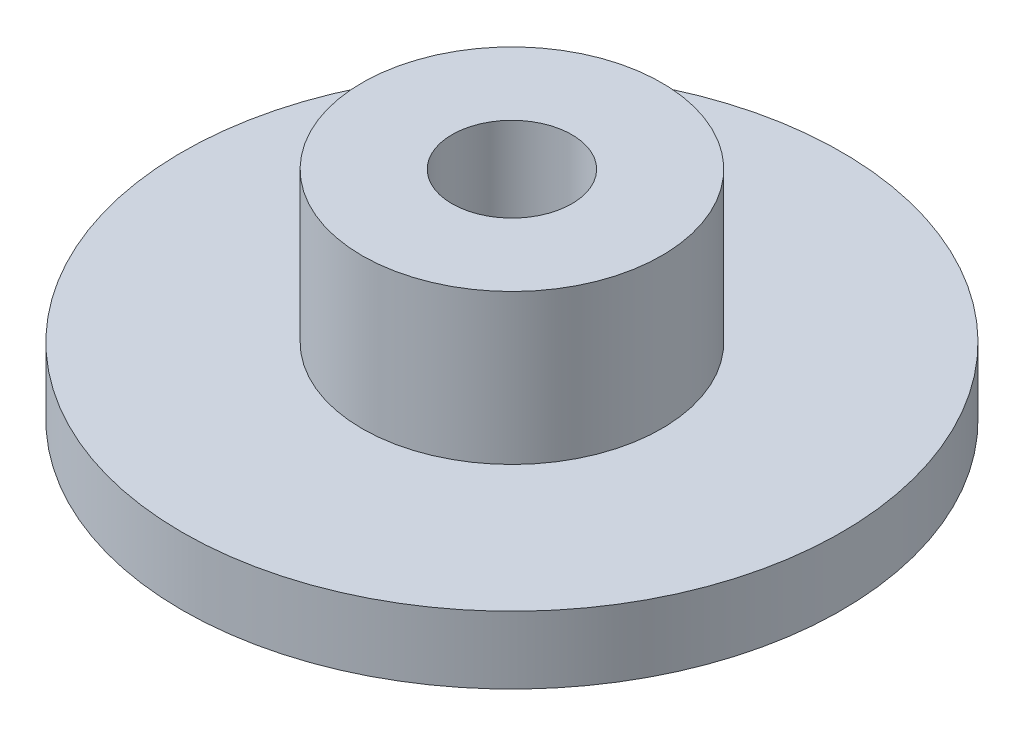
from build123d import *

# Parameters (mm, degrees)
SKETCH1_R           = 22
BOSS_EXTRUDE1_DEPTH = 4.5
SKETCH3_R           = 10
BOSS_EXTRUDE2_DEPTH = 10
SKETCH4_R           = 4
CUT_EXTRUDE1_DEPTH  = 15


with BuildPart() as part:
    # Sketch1 → Boss-Extrude1 (new body)
    with BuildSketch(Plane(origin=(0, 0, 0), x_dir=(1, 0, 0), z_dir=(0, 1, 0))):
        Circle(SKETCH1_R)
    extrude(amount=BOSS_EXTRUDE1_DEPTH)

    # Sketch3 → Boss-Extrude2 (add)
    with BuildSketch(Plane(origin=(0, 4.5, 0), x_dir=(1, 0, 0), z_dir=(0, 1, 0))):
        Circle(SKETCH3_R)
    extrude(amount=BOSS_EXTRUDE2_DEPTH)

    # Sketch4 → Cut-Extrude1 (cut)
    with BuildSketch(Plane(origin=(0, 14.5, 0), x_dir=(1, 0, 0), z_dir=(0, 1, 0))):
        Circle(SKETCH4_R)
    extrude(amount=-CUT_EXTRUDE1_DEPTH, mode=Mode.SUBTRACT)


solid = part.part
